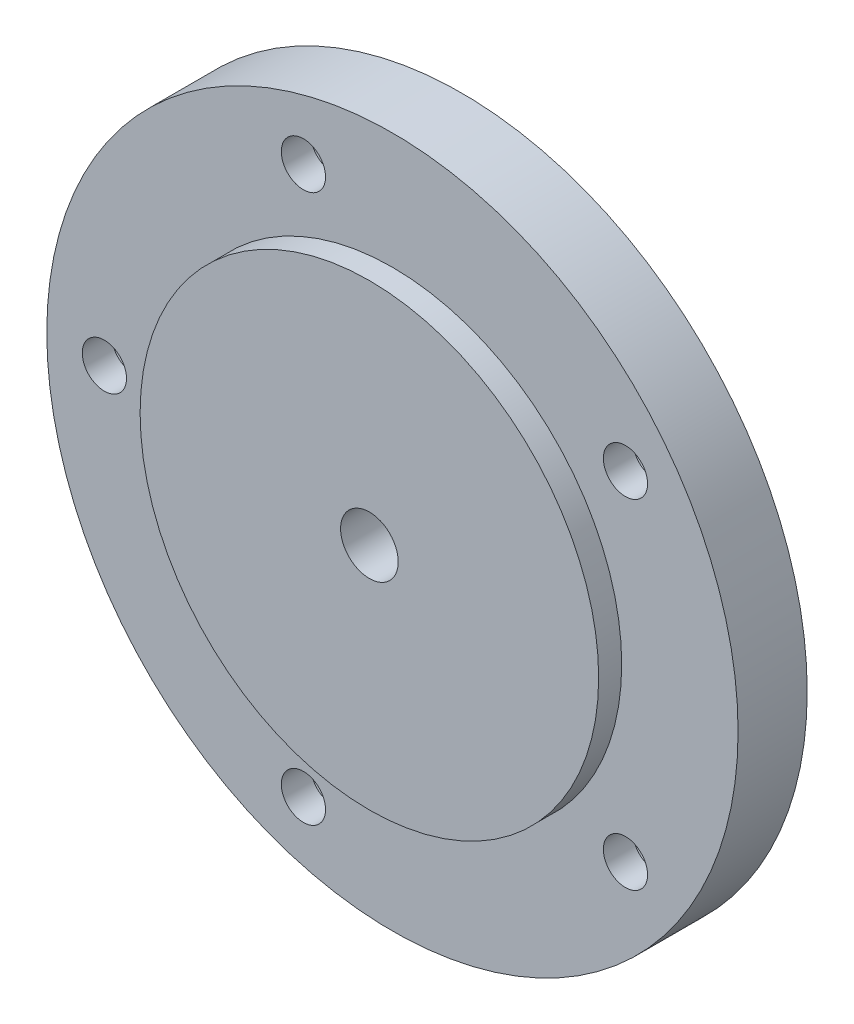
from build123d import *

# Parameters (mm, degrees)
SKETCH1_R                                      = 19.05
BOSS_EXTRUDE1_DEPTH                            = 3.81
SKETCH2_R                                      = 12.6365
BOSS_EXTRUDE2_DEPTH                            = 1.27
CBORE_FOR_2_SOCKET_HEAD_CAP_SCREW1_D           = 2.4384
CBORE_FOR_2_SOCKET_HEAD_CAP_SCREW1_CBORE_D     = 4.7625
CBORE_FOR_2_SOCKET_HEAD_CAP_SCREW1_CBORE_DEPTH = 2.1844
CIRPATTERN1_COUNT                              = 5
F_1_8_0_1250_DOWEL_HOLE1_D                     = 3.175


with BuildPart() as part:
    # Sketch1 → Boss-Extrude1 (new body)
    with BuildSketch(Plane.XY):
        Circle(SKETCH1_R)
    extrude(amount=BOSS_EXTRUDE1_DEPTH)

    # Sketch2 → Boss-Extrude2 (add)
    with BuildSketch(Plane.XY.offset(3.81)):
        Circle(SKETCH2_R)
    extrude(amount=BOSS_EXTRUDE2_DEPTH)

    # CBORE for _2 Socket Head Cap Screw1 (through all)
    with Locations(Plane(origin=(0, 0, 0), x_dir=(-1, 0, 0), z_dir=(0, 0, -1))):
        with Locations((15.875, 0)):
            cbore_for_2_socket_head_cap_screw1 = CounterBoreHole(CBORE_FOR_2_SOCKET_HEAD_CAP_SCREW1_D / 2, CBORE_FOR_2_SOCKET_HEAD_CAP_SCREW1_CBORE_D / 2, CBORE_FOR_2_SOCKET_HEAD_CAP_SCREW1_CBORE_DEPTH)

    # CirPattern1: CBORE for _2 Socket Head Cap Screw1 ×5 about axis
    cirpattern1_axis = Axis((0, 0, 0), (0, 0, -1))
    for i in range(1, CIRPATTERN1_COUNT):
        add(cbore_for_2_socket_head_cap_screw1.rotate(cirpattern1_axis, i * 360 / CIRPATTERN1_COUNT), mode=Mode.SUBTRACT)

    # 1_8 _0.1250_ Dowel Hole1 (through all)
    with Locations(Plane(origin=(0, 0, 0), x_dir=(-1, 0, 0), z_dir=(0, 0, -1))):
        with Locations((0, 0)):
            Hole(F_1_8_0_1250_DOWEL_HOLE1_D / 2)


solid = part.part
